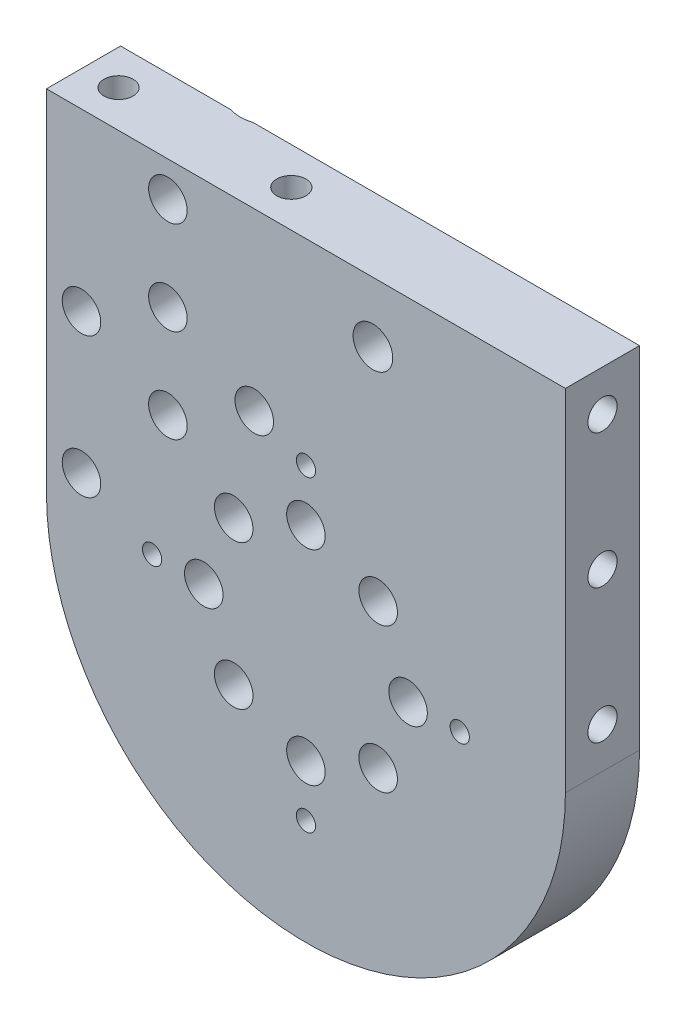
from build123d import *

# Parameters (mm, degrees)
BOSS_EXTRUDE1_DEPTH                                 = 12.7
F_4_CLEARANCE_HOLE1_D                               = 3.3
F_4_CLEARANCE_HOLE1_DEPTH                           = 12.7
F_1_4_CLEARANCE_HOLE1_D                             = 6.6
F_1_4_CLEARANCE_HOLE1_DEPTH                         = 12.7
F_1_4_CLEARANCE_HOLE2_D                             = 6.8
F_1_4_CLEARANCE_HOLE2_DEPTH                         = 12.7
CSK_FOR_1_4_FLAT_HEAD_MACHINE_SCREW_100_D           = 6.6
CSK_FOR_1_4_FLAT_HEAD_MACHINE_SCREW_100_DEPTH       = 12.7
CSK_FOR_1_4_FLAT_HEAD_MACHINE_SCREW_100_CSINK_D     = 12.6
CSK_FOR_1_4_FLAT_HEAD_MACHINE_SCREW_100_CSINK_ANGLE = 90
F_10_CLEARANCE_HOLE1_D                              = 5
F_10_CLEARANCE_HOLE1_DEPTH                          = 15
F_10_CLEARANCE_HOLE2_D                              = 5
F_10_CLEARANCE_HOLE2_DEPTH                          = 10
F_1_3_4_CLEARANCE_HOLE1_D                           = 45
F_1_3_4_CLEARANCE_HOLE1_DEPTH                       = 5
F_1_4_CLEARANCE_HOLE3_D                             = 6.6
F_1_4_CLEARANCE_HOLE3_DEPTH                         = 12.7
CHAMFER1_SIZE                                       = 3


with BuildPart() as part:
    # Sketch1 → Boss-Extrude1 (new body)
    with BuildSketch(Plane(origin=(0, 0, 0), x_dir=(-1, 0, 0), z_dir=(0, 0, -1))):
        with BuildLine():
            Line((44.45, 0), (44.45, 60))
            Line((44.45, 60), (-44.45, 60))
            Line((-44.45, 60), (-44.45, 0))
            ThreePointArc((-44.45, 0), (0, -44.45), (44.45, 0))
        make_face()
    extrude(amount=-BOSS_EXTRUDE1_DEPTH)

    # #4 Clearance Hole1
    with Locations(Plane.XY.offset(12.7)):
        with Locations((26.35, 0), (0, -26.35), (-26.35, 0), (0, 26.35)):
            Hole(F_4_CLEARANCE_HOLE1_D / 2, depth=F_4_CLEARANCE_HOLE1_DEPTH)

    # 1/4 Clearance Hole1
    with Locations(Plane(origin=(0, 0, 0), x_dir=(-1, 0, 0), z_dir=(0, 0, -1))):
        with Locations((8.85, 30), (23.65, 38), (23.65, 22)):
            Hole(F_1_4_CLEARANCE_HOLE1_D / 2, depth=F_1_4_CLEARANCE_HOLE1_DEPTH)

    # 1/4 Clearance Hole2
    with Locations(Plane.XY.offset(12.7)):
        with Locations((11.472503772, 49.692873304)):
            Hole(F_1_4_CLEARANCE_HOLE2_D / 2, depth=F_1_4_CLEARANCE_HOLE2_DEPTH)

    # CSK for 1/4 Flat Head Machine Screw (100)1
    with Locations(Plane(origin=(0, 0, 0), x_dir=(-1, 0, 0), z_dir=(0, 0, -1))):
        with Locations((23.65, 54), (38.45, 6), (38.45, 30)):
            CounterSinkHole(CSK_FOR_1_4_FLAT_HEAD_MACHINE_SCREW_100_D / 2, CSK_FOR_1_4_FLAT_HEAD_MACHINE_SCREW_100_CSINK_D / 2, depth=CSK_FOR_1_4_FLAT_HEAD_MACHINE_SCREW_100_DEPTH, counter_sink_angle=CSK_FOR_1_4_FLAT_HEAD_MACHINE_SCREW_100_CSINK_ANGLE)

    # #10 Clearance Hole1
    with Locations(Plane(origin=(0, 60, 0), x_dir=(1, 0, 0), z_dir=(0, 1, 0))):
        with Locations((-38.45, -6.35), (-8.85, -6.35)):
            Hole(F_10_CLEARANCE_HOLE1_D / 2, depth=F_10_CLEARANCE_HOLE1_DEPTH)

    # #10 Clearance Hole2
    with Locations(Plane(origin=(44.45, 0, 0), x_dir=(0, 0, -1), z_dir=(1, 0, 0))):
        with Locations((-6.35, 7), (-6.35, 53), (-6.35, 30)):
            Hole(F_10_CLEARANCE_HOLE2_D / 2, depth=F_10_CLEARANCE_HOLE2_DEPTH)

    # 1-3/4 Clearance Hole1
    with Locations(Plane(origin=(0, 0, 0), x_dir=(-1, 0, 0), z_dir=(0, 0, -1))):
        with Locations((0, 0)):
            Hole(F_1_3_4_CLEARANCE_HOLE1_D / 2, depth=F_1_3_4_CLEARANCE_HOLE1_DEPTH)

    # 1/4 Clearance Hole3
    with Locations(Plane.XY.offset(12.7)):
        with Locations((12.374075778, 12.373661564), (17.499, -0.001), (12.372661564, -12.375075778), (-0.002, -17.5), (-12.376075778, -12.373661564), (-17.501, 0.001), (-12.374661564, 12.375075778), (0, 17.5)):
            Hole(F_1_4_CLEARANCE_HOLE3_D / 2, depth=F_1_4_CLEARANCE_HOLE3_DEPTH)

    # Chamfer1
    chamfer1_edges = [part.edges().sort_by_distance(p)[0] for p in [
        (-26.95, 22, 0),
        (-26.95, 38, 0),
        (-12.15, 30, 0),
    ]]
    chamfer(chamfer1_edges, length=CHAMFER1_SIZE)


solid = part.part
